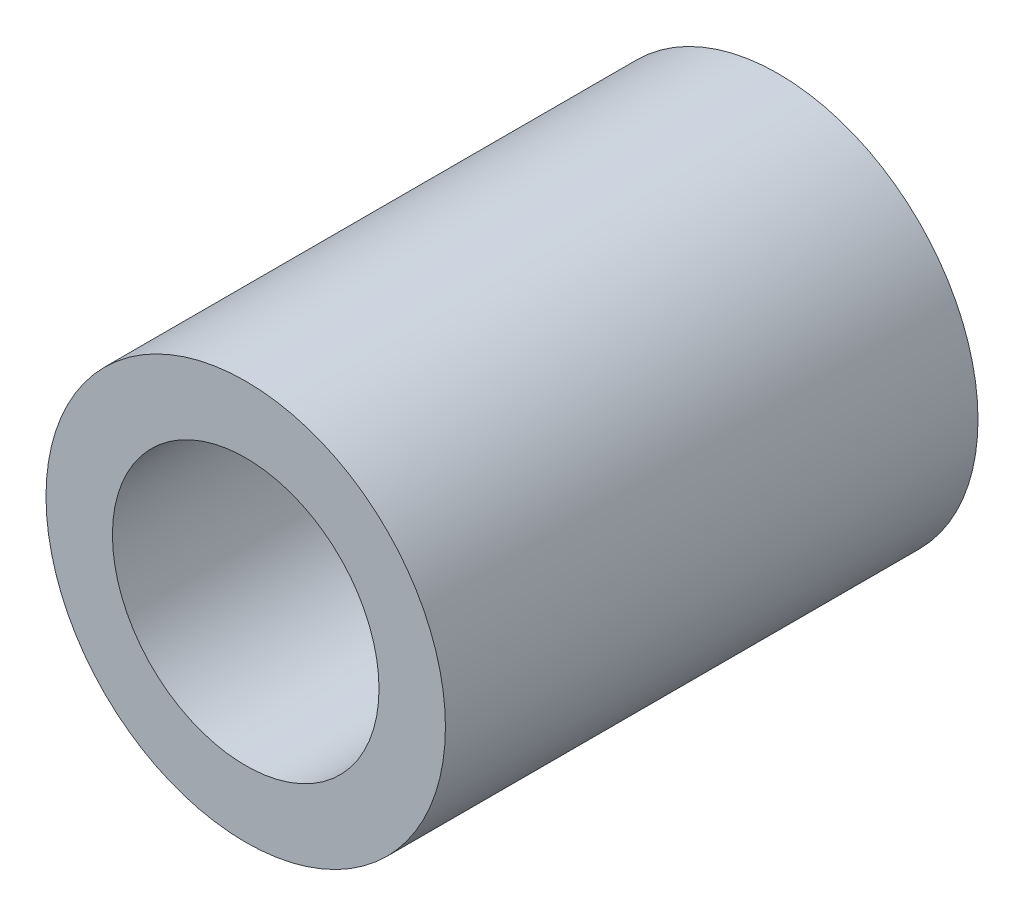
from build123d import *

# Parameters (mm, degrees)
SKETCH3_R                = 4.7625
SKETCH3_R_2              = 3.17881
BOSS_EXTRUDE1_DEPTH      = 6.35
BOSS_EXTRUDE1_DEPTH_BACK = 6.35


with BuildPart() as part:
    # Sketch3 → Boss-Extrude1 (new body, two sides)
    with BuildSketch(Plane.XY) as boss_extrude1_sk:
        Circle(SKETCH3_R)
        Circle(SKETCH3_R_2, mode=Mode.SUBTRACT)
    extrude(amount=BOSS_EXTRUDE1_DEPTH)
    extrude(boss_extrude1_sk.sketch, amount=-BOSS_EXTRUDE1_DEPTH_BACK)


solid = part.part
